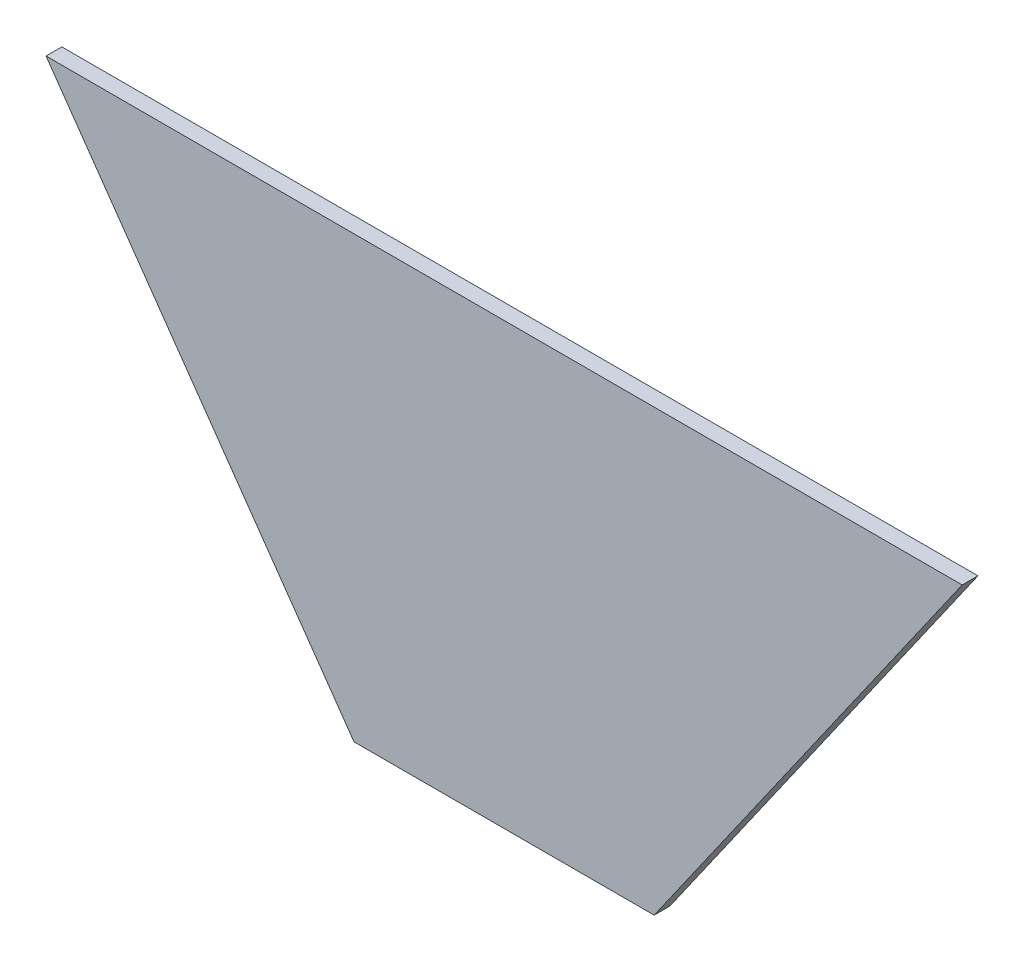
from build123d import *

# Parameters (mm, degrees)
BOSS_EXTRUDE1_DEPTH = 10


with BuildPart() as part:
    # Sketch1 → Boss-Extrude1 (new body)
    with BuildSketch(Plane.XY):
        Polygon((-95, 0), (95, 0), (290, 278.522889544), (-290, 278.522889544), align=None)
    extrude(amount=BOSS_EXTRUDE1_DEPTH)


solid = part.part
